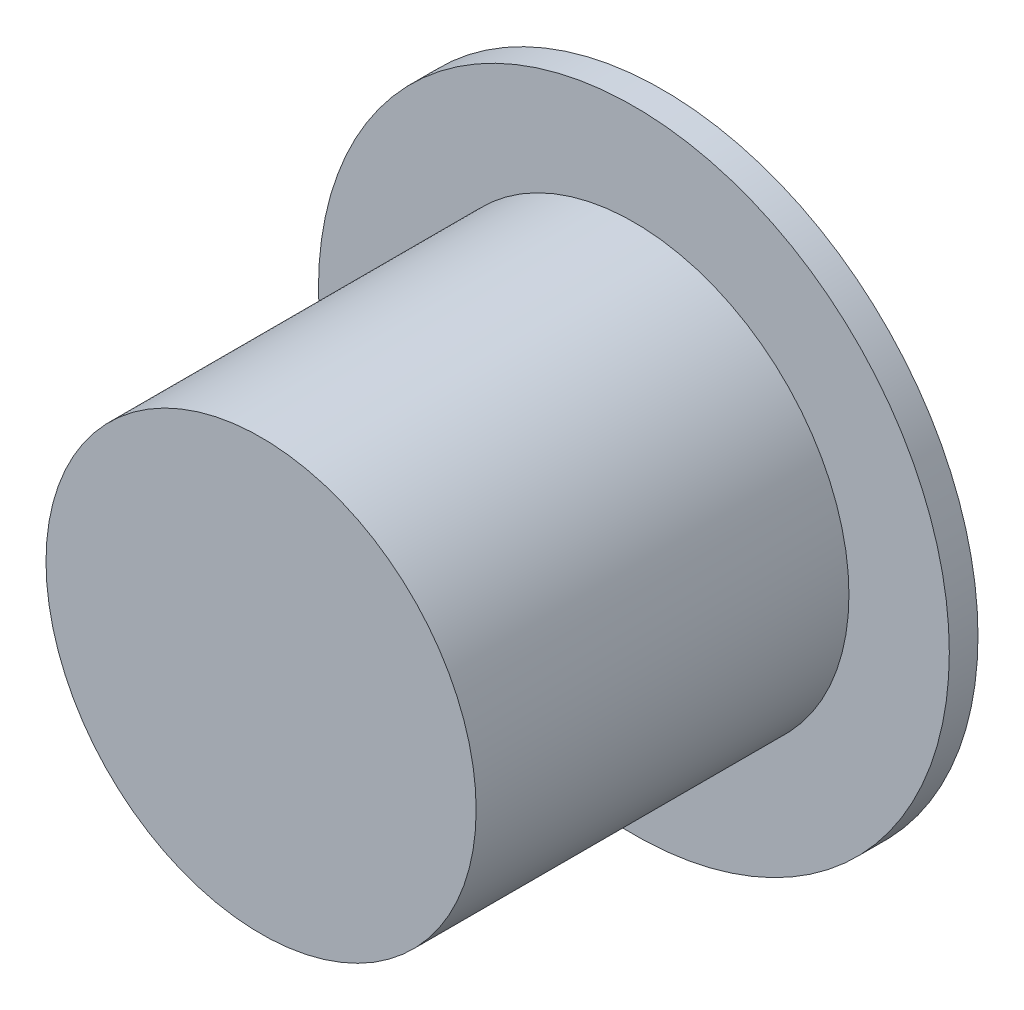
from build123d import *

# Parameters (mm, degrees)
SKETCH1_R           = 7.5
SKETCH1_W           = 6.85
SKETCH1_H           = 6.85
BOSS_EXTRUDE1_DEPTH = 6
SKETCH2_R           = 11
SKETCH2_R_2         = 7.5
BOSS_EXTRUDE2_DEPTH = 1
BOSS_EXTRUDE3_START = 6
SKETCH1_2_R         = 7.5
SKETCH1_2_W         = 6.85
SKETCH1_2_H         = 6.85
BOSS_EXTRUDE3_DEPTH = 2


with BuildPart() as part:
    # Sketch1 → Boss-Extrude1 (new, symmetric)
    with BuildSketch(Plane.XY):
        Circle(SKETCH1_R)
        Rectangle(SKETCH1_W, SKETCH1_H, mode=Mode.SUBTRACT)
    extrude(amount=BOSS_EXTRUDE1_DEPTH, both=True)

    # Sketch2 → Boss-Extrude2 (add)
    with BuildSketch(Plane(origin=(0, 0, -6), x_dir=(-1, 0, 0), z_dir=(0, 0, -1))):
        Circle(SKETCH2_R)
        Circle(SKETCH2_R_2, mode=Mode.SUBTRACT)
    extrude(amount=-BOSS_EXTRUDE2_DEPTH)

    # Sketch1_2 → Boss-Extrude3 (add)
    with BuildSketch(Plane.XY.offset(BOSS_EXTRUDE3_START)):
        with Locations(Location((0, 0, 0), (0, 0, 180))):
            Circle(SKETCH1_2_R)
        Rectangle(SKETCH1_2_W, SKETCH1_2_H, mode=Mode.SUBTRACT)
        Rectangle(SKETCH1_2_W, SKETCH1_2_H)
    extrude(amount=BOSS_EXTRUDE3_DEPTH)


solid = part.part
